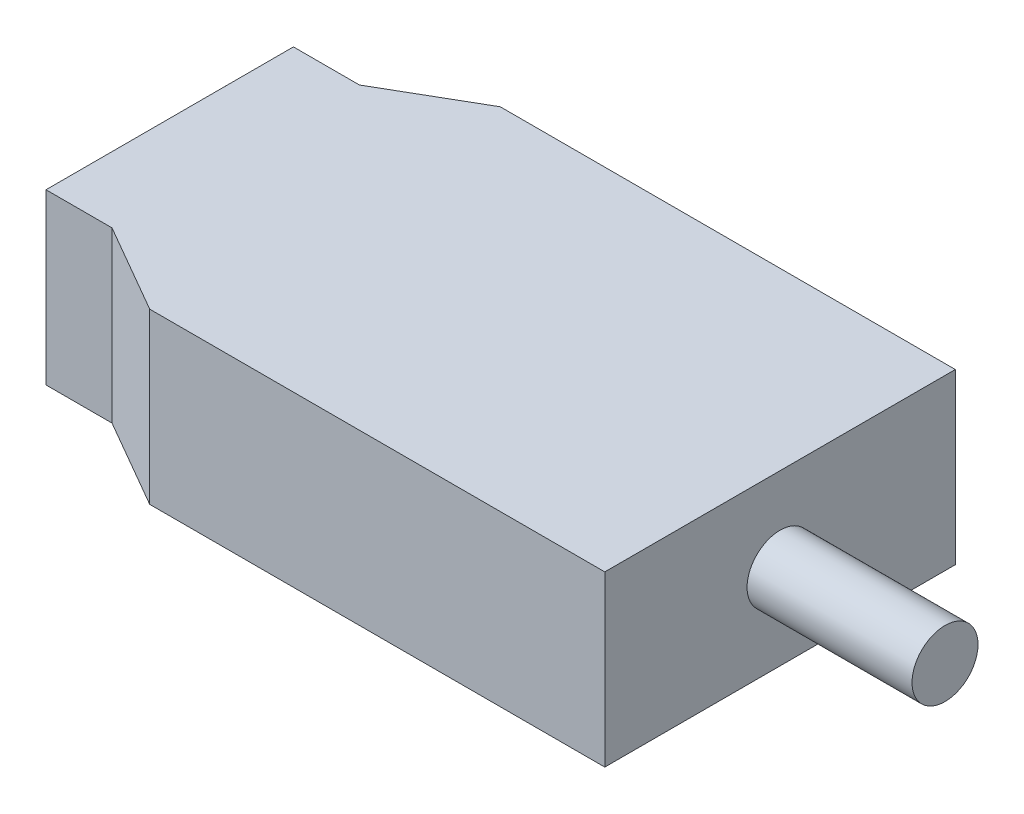
from build123d import *

# Parameters (mm, degrees)
AUFSATZ_LINEAR_AUSTRAGEN1_DEPTH      = 10.25
AUFSATZ_LINEAR_AUSTRAGEN1_DEPTH_BACK = 10.25
SKIZZE2_R                            = 4
AUFSATZ_LINEAR_AUSTRAGEN2_DEPTH      = 20


with BuildPart() as part:
    # Skizze1 → Aufsatz-Linear austragen1 (new, two sides: drawn at the far end of the back side and taken through both)
    with BuildSketch(Plane(origin=(0, 0, 0), x_dir=(1, 0, 0), z_dir=(0, 1, 0)).offset(-AUFSATZ_LINEAR_AUSTRAGEN1_DEPTH_BACK)):
        Polygon((0, 21.25), (0, -21.25), (-55.174682453, -21.25), (-66, -15), (-74, -15), (-74, 15), (-66, 15), (-55.174682453, 21.25), align=None)
    extrude(amount=AUFSATZ_LINEAR_AUSTRAGEN1_DEPTH + AUFSATZ_LINEAR_AUSTRAGEN1_DEPTH_BACK)

    # Skizze2 → Aufsatz-Linear austragen2 (add)
    with BuildSketch(Plane(origin=(0, 0, 0), x_dir=(0, 0, -1), z_dir=(1, 0, 0))):
        Circle(SKIZZE2_R)
    extrude(amount=AUFSATZ_LINEAR_AUSTRAGEN2_DEPTH)


solid = part.part
